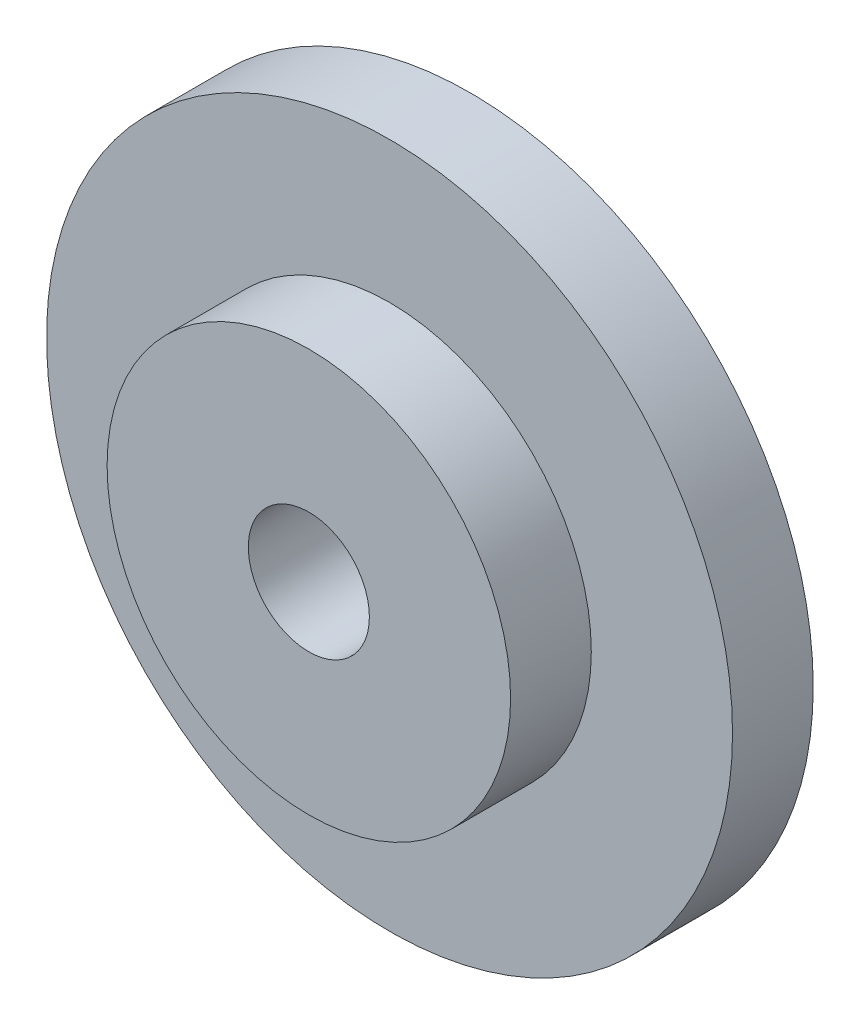
from build123d import *

# Parameters (mm, degrees)
SKETCH1_R           = 8.5
BOSS_EXTRUDE1_DEPTH = 2
SKETCH2_R           = 5
BOSS_EXTRUDE2_DEPTH = 2
SKETCH3_R           = 1.5
CUT_EXTRUDE1_DEPTH  = 5


with BuildPart() as part:
    # Sketch1 → Boss-Extrude1 (new body)
    with BuildSketch(Plane.XY):
        Circle(SKETCH1_R)
    extrude(amount=BOSS_EXTRUDE1_DEPTH)

    # Sketch2 → Boss-Extrude2 (add)
    with BuildSketch(Plane.XY.offset(2)):
        Circle(SKETCH2_R)
    extrude(amount=BOSS_EXTRUDE2_DEPTH)

    # Sketch3 → Cut-Extrude1 (cut, through all)
    with BuildSketch(Plane.XY.offset(4)):
        Circle(SKETCH3_R)
    extrude(amount=-CUT_EXTRUDE1_DEPTH, mode=Mode.SUBTRACT)


solid = part.part
